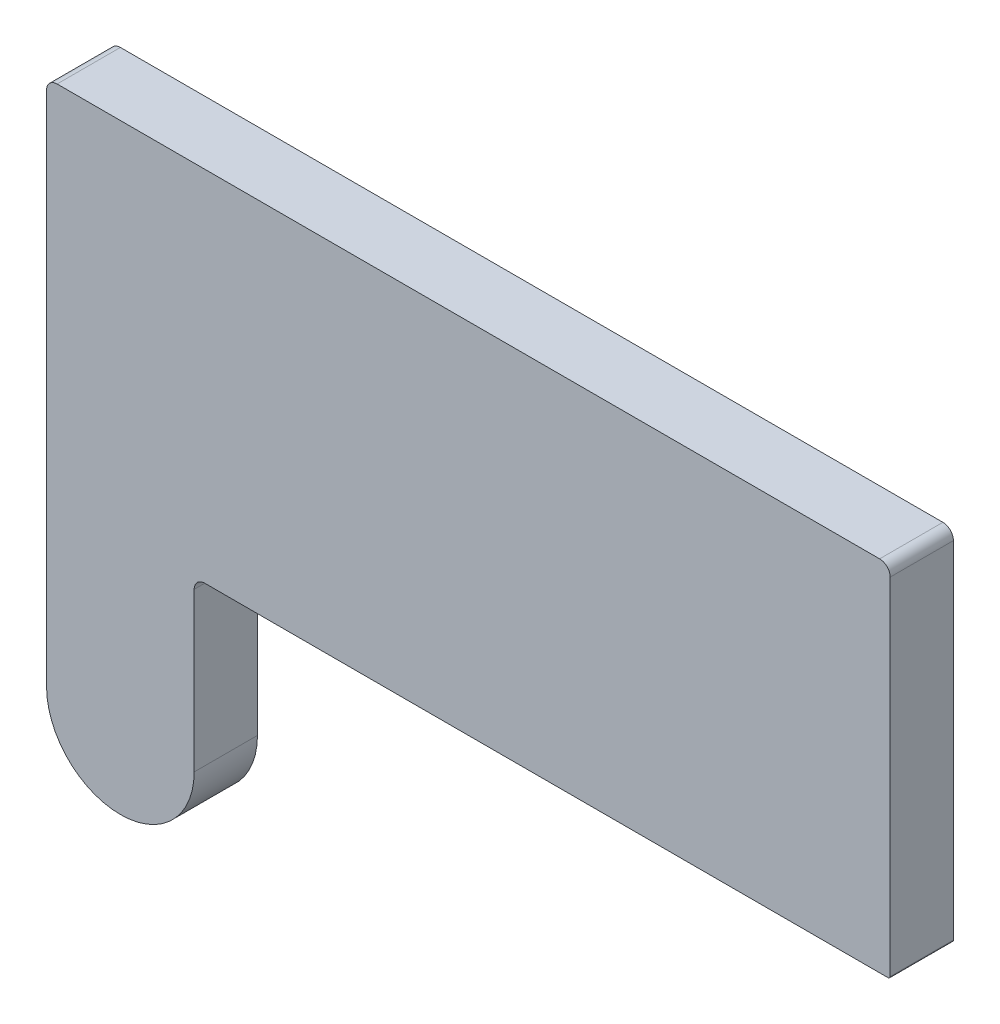
from build123d import *

# Parameters (mm, degrees)
BODY_DEPTH = 1.5


with BuildPart() as part:
    # Sketch1 → Body (new body, symmetric)
    with BuildSketch(Plane.XY):
        with BuildLine():
            Line((0, 0), (0, 24.5))
            ThreePointArc((0, 24.5), (0.146446609, 24.853553391), (0.5, 25))
            Line((0.5, 25), (28.339745962, 25))
            Line((28.339745962, 25), (39.5, 25))
            ThreePointArc((39.5, 25), (39.853553391, 24.853553391), (40, 24.5))
            Line((40, 24.5), (40, 8.1))
            ThreePointArc((40, 8.1), (39.970710678, 8.029289322), (39.9, 8))
            Line((39.9, 8), (36.966924922, 8))
            Line((36.966924922, 8), (7.5, 8))
            ThreePointArc((7.5, 8), (7.146446609, 7.853553391), (7, 7.5))
            Line((7, 7.5), (7, 0))
            ThreePointArc((7, 0), (3.5, -3.5), (0, 0))
        make_face()
    extrude(amount=BODY_DEPTH, both=True)


solid = part.part
